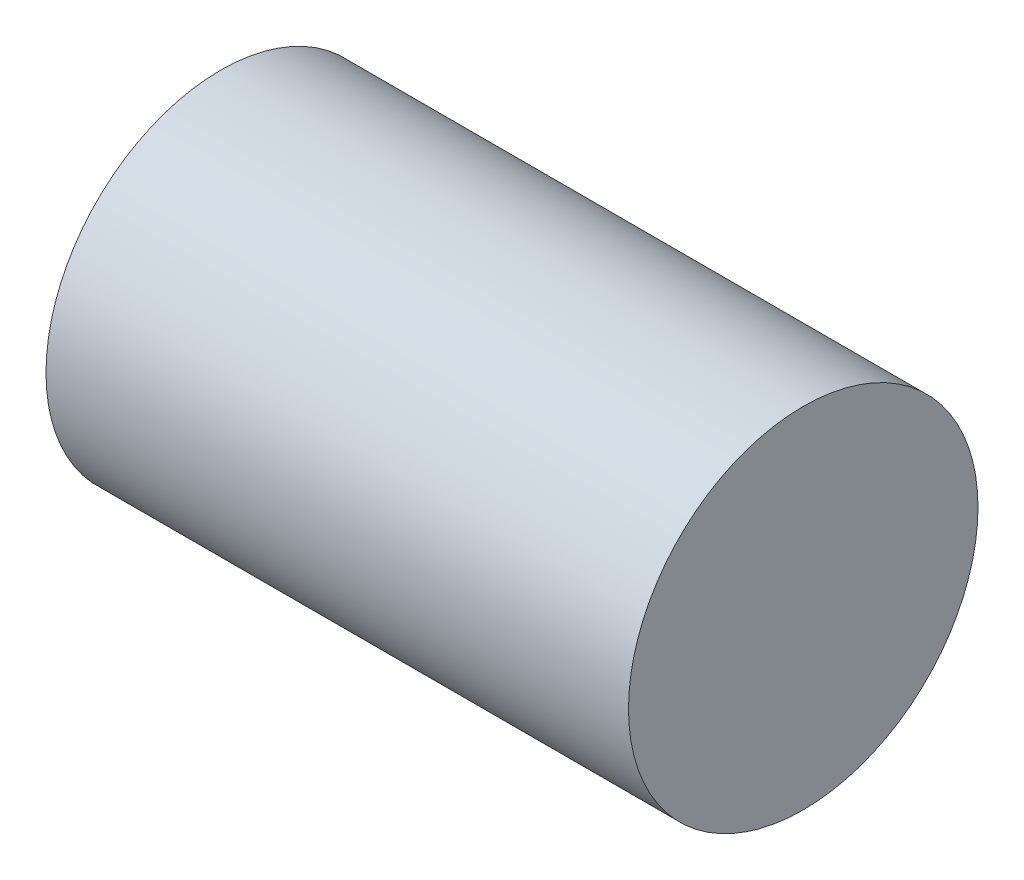
from build123d import *

# Parameters (mm, degrees)
SCHIZZO1_W = 40
SCHIZZO1_H = 12


with BuildPart() as part:
    # Schizzo1 → Rivoluzione1 (revolve)
    with BuildSketch(Plane.XY):
        with Locations((20, 6)):
            Rectangle(SCHIZZO1_W, SCHIZZO1_H)
    revolve(axis=Axis((0, 12, 0), (1, 0, 0)))


solid = part.part
